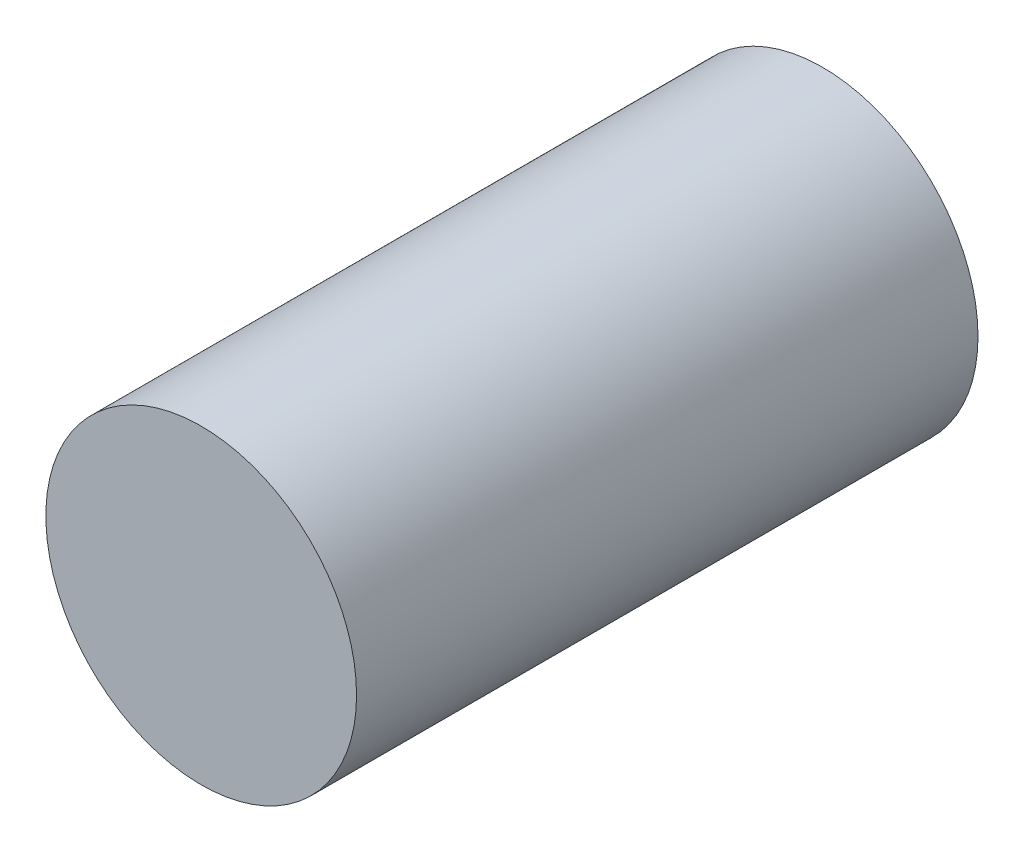
from build123d import *

# Parameters (mm, degrees)
SKETCH_1_R      = 3
EXTRUDE_1_DEPTH = 12


with BuildPart() as part:
    # 草图1 → 凸台-拉伸1 (new body)
    with BuildSketch(Plane.XY):
        Circle(SKETCH_1_R)
    extrude(amount=EXTRUDE_1_DEPTH)


solid = part.part
